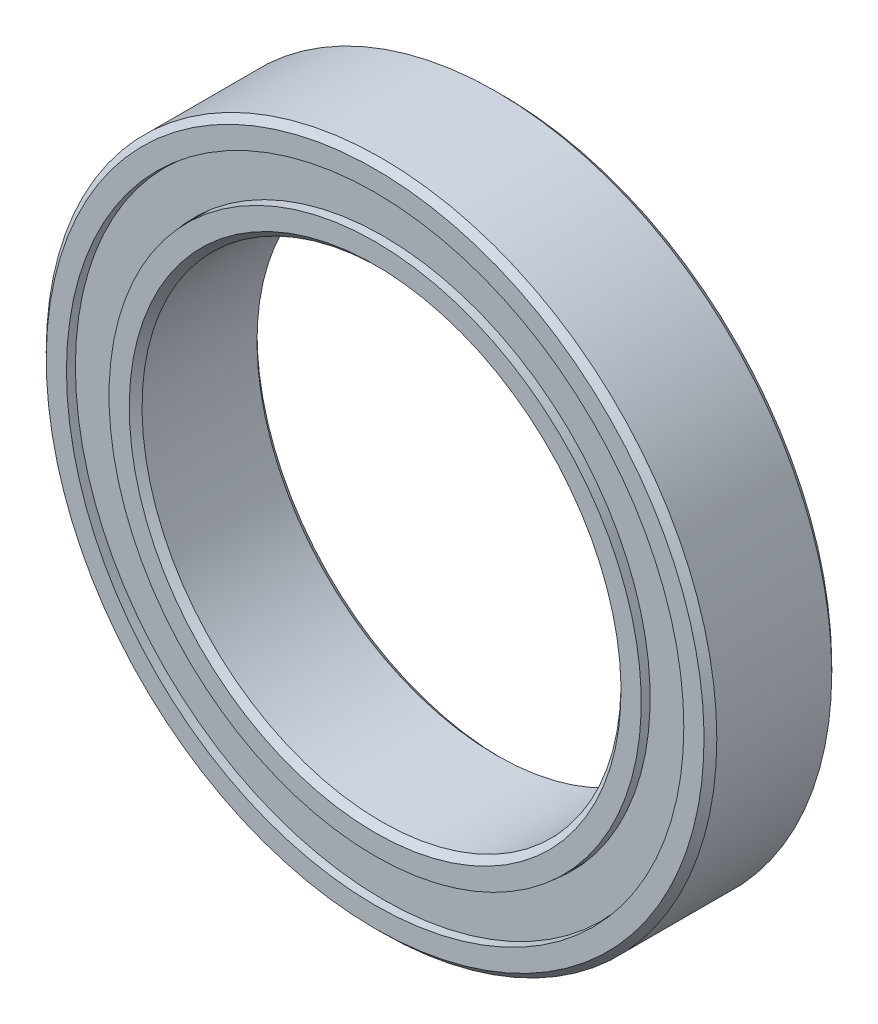
from build123d import *

# Parameters (mm, degrees)
SKETCH5_W         = 0.381
SKETCH5_H         = 1.282533334
CIRPATTERN1_COUNT = 14


with BuildPart() as part:
    # Sketch5 → Revolve1 (revolve)
    with BuildSketch(Plane(origin=(0, 0, 0), x_dir=(0, 0, -1), z_dir=(1, 0, 0))):
        with BuildLine():
            Line((1.8, 10.5), (-1.8, 10.5))
            Line((-1.8, 10.5), (-2, 10.3))
            Line((-2, 10.3), (-2, 9.666666667))
            Line((-2, 9.666666667), (-0.888888889, 9.666666667))
            ThreePointArc((-0.888888889, 9.666666667), (0, 10.111111111), (0.888888889, 9.666666667))
            Line((0.888888889, 9.666666667), (2, 9.666666667))
            Line((2, 9.666666667), (2, 10.3))
            Line((2, 10.3), (1.8, 10.5))
        make_face()
        with Locations((1.555555556, 9)):
            Rectangle(SKETCH5_W, SKETCH5_H)
        with Locations((-1.555555556, 9)):
            Rectangle(SKETCH5_W, SKETCH5_H)
    revolve(axis=Axis((0, 0, 2), (0, 0, -1)))


with BuildPart() as body_2:
    # Sketch3 → Revolve3 (revolve)
    with BuildSketch(Plane(origin=(0, 0, 0), x_dir=(0, 0, -1), z_dir=(1, 0, 0))):
        with BuildLine():
            Line((-2, 8.333333333), (-0.888888889, 8.333333333))
            ThreePointArc((-0.888888889, 8.333333333), (0, 7.888888889), (0.888888889, 8.333333333))
            Line((0.888888889, 8.333333333), (2, 8.333333333))
            Line((2, 8.333333333), (2, 7.7))
            Line((2, 7.7), (1.8, 7.5))
            Line((1.8, 7.5), (-1.8, 7.5))
            Line((-1.8, 7.5), (-2, 7.7))
            Line((-2, 7.7), (-2, 8.333333333))
        make_face()
    revolve(axis=Axis((0, 0, 2), (0, 0, -1)))


with BuildPart() as body_3:
    # Sketch4 → Revolve4 (revolve)
    with BuildSketch(Plane(origin=(0, 0, 0), x_dir=(0, 0, -1), z_dir=(1, 0, 0))):
        with BuildLine():
            Line((-1.111111111, 9), (1.111111111, 9))
            ThreePointArc((1.111111111, 9), (0, 10.111111111), (-1.111111111, 9))
        make_face()
    revolve(axis=Axis((0, 9, 1.111111111), (0, 0, -1)))


with BuildPart() as cirpattern1_1:
    # CirPattern1: pattern copy
    add(body_3.part.rotate(Axis((0, 0, 0), (0, 0, 1)), 1 * 360 / CIRPATTERN1_COUNT))


with BuildPart() as cirpattern1_2:
    # CirPattern1: pattern copy
    add(body_3.part.rotate(Axis((0, 0, 0), (0, 0, 1)), 2 * 360 / CIRPATTERN1_COUNT))


with BuildPart() as cirpattern1_3:
    # CirPattern1: pattern copy
    add(body_3.part.rotate(Axis((0, 0, 0), (0, 0, 1)), 3 * 360 / CIRPATTERN1_COUNT))


with BuildPart() as cirpattern1_4:
    # CirPattern1: pattern copy
    add(body_3.part.rotate(Axis((0, 0, 0), (0, 0, 1)), 4 * 360 / CIRPATTERN1_COUNT))


with BuildPart() as cirpattern1_5:
    # CirPattern1: pattern copy
    add(body_3.part.rotate(Axis((0, 0, 0), (0, 0, 1)), 5 * 360 / CIRPATTERN1_COUNT))


with BuildPart() as cirpattern1_6:
    # CirPattern1: pattern copy
    add(body_3.part.rotate(Axis((0, 0, 0), (0, 0, 1)), 6 * 360 / CIRPATTERN1_COUNT))


with BuildPart() as cirpattern1_7:
    # CirPattern1: pattern copy
    add(body_3.part.rotate(Axis((0, 0, 0), (0, 0, 1)), 7 * 360 / CIRPATTERN1_COUNT))


with BuildPart() as cirpattern1_8:
    # CirPattern1: pattern copy
    add(body_3.part.rotate(Axis((0, 0, 0), (0, 0, 1)), 8 * 360 / CIRPATTERN1_COUNT))


with BuildPart() as cirpattern1_9:
    # CirPattern1: pattern copy
    add(body_3.part.rotate(Axis((0, 0, 0), (0, 0, 1)), 9 * 360 / CIRPATTERN1_COUNT))


with BuildPart() as cirpattern1_10:
    # CirPattern1: pattern copy
    add(body_3.part.rotate(Axis((0, 0, 0), (0, 0, 1)), 10 * 360 / CIRPATTERN1_COUNT))


with BuildPart() as cirpattern1_11:
    # CirPattern1: pattern copy
    add(body_3.part.rotate(Axis((0, 0, 0), (0, 0, 1)), 11 * 360 / CIRPATTERN1_COUNT))


with BuildPart() as cirpattern1_12:
    # CirPattern1: pattern copy
    add(body_3.part.rotate(Axis((0, 0, 0), (0, 0, 1)), 12 * 360 / CIRPATTERN1_COUNT))


with BuildPart() as cirpattern1_13:
    # CirPattern1: pattern copy
    add(body_3.part.rotate(Axis((0, 0, 0), (0, 0, 1)), 13 * 360 / CIRPATTERN1_COUNT))


solid = Compound([part.part, body_2.part, body_3.part, cirpattern1_1.part, cirpattern1_2.part, cirpattern1_3.part, cirpattern1_4.part, cirpattern1_5.part, cirpattern1_6.part, cirpattern1_7.part, cirpattern1_8.part, cirpattern1_9.part, cirpattern1_10.part, cirpattern1_11.part, cirpattern1_12.part, cirpattern1_13.part])
